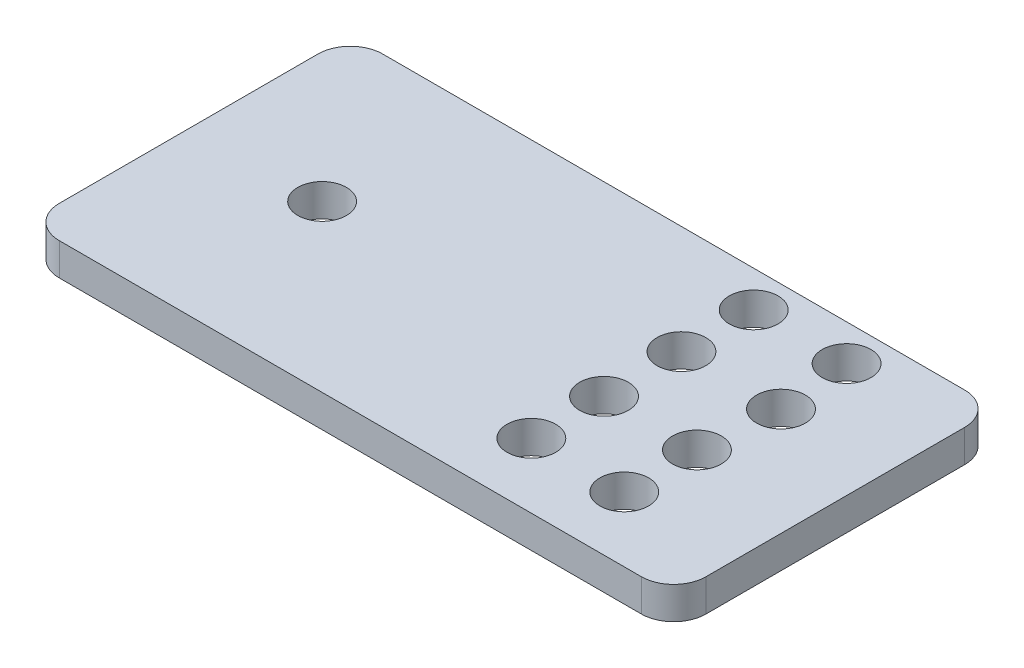
from build123d import *

# Parameters (mm, degrees)
BOSS_EXTRUDE1_DEPTH = 10
SKETCH3_R           = 7.535275438
CUT_EXTRUDE10_DEPTH = 10


with BuildPart() as part:
    # Sketch1 → Boss-Extrude1 (new body)
    with BuildSketch(Plane(origin=(0, 0, 0), x_dir=(1, 0, 0), z_dir=(0, 1, 0))):
        with BuildLine():
            Line((73.562221188, 48.852459016), (-106.437778812, 48.852459016))
            ThreePointArc((-106.437778812, 48.852459016), (-113.508846624, 45.923526828), (-116.437778812, 38.852459016))
            Line((-116.437778812, 38.852459016), (-116.437778812, -41.147540984))
            ThreePointArc((-116.437778812, -41.147540984), (-113.508846624, -48.218608795), (-106.437778812, -51.147540984))
            Line((-106.437778812, -51.147540984), (73.562221188, -51.147540984))
            ThreePointArc((73.562221188, -51.147540984), (80.633289, -48.218608795), (83.562221188, -41.147540984))
            Line((83.562221188, -41.147540984), (83.562221188, 38.852459016))
            ThreePointArc((83.562221188, 38.852459016), (80.633289, 45.923526828), (73.562221188, 48.852459016))
        make_face()
    extrude(amount=BOSS_EXTRUDE1_DEPTH)

    # Sketch3 → Cut-Extrude10 (cut)
    with BuildSketch(Plane(origin=(0, 0, 0), x_dir=(1, 0, 0), z_dir=(0, 1, 0))):
        with Locations((48.215632939, 37.678714221)):
            Circle(SKETCH3_R)
        with Locations((19.480783272, 37.678714221)):
            Circle(SKETCH3_R)
        with Locations((48.215632939, -31.079676053)):
            Circle(SKETCH3_R)
        with Locations((19.480783272, -31.079676053)):
            Circle(SKETCH3_R)
        with Locations((-76.302048951, 0)):
            Circle(SKETCH3_R)
        with Locations((19.480783272, -8.606914665)):
            Circle(SKETCH3_R)
        with Locations((48.215632939, -8.606914665)):
            Circle(SKETCH3_R)
        with Locations((19.480783272, 15.338793391)):
            Circle(SKETCH3_R)
        with Locations((50.268122201, 15.338793391)):
            Circle(SKETCH3_R)
    extrude(amount=CUT_EXTRUDE10_DEPTH, mode=Mode.SUBTRACT)


solid = part.part
